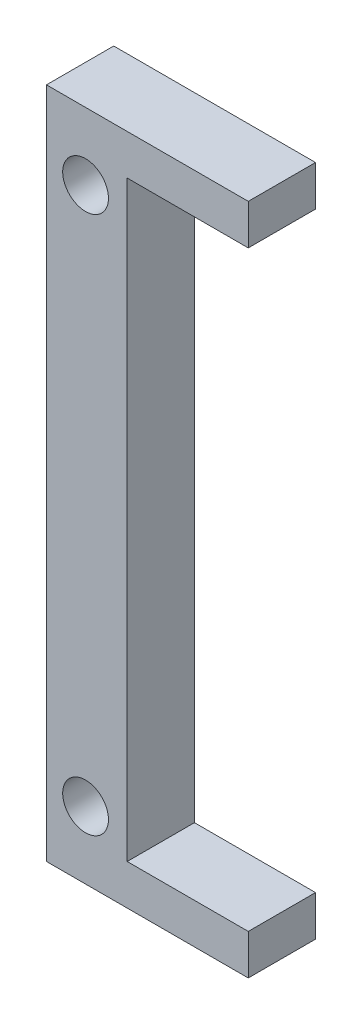
from build123d import *

# Parameters (mm, degrees)
BOSS_EXTRUDE1_DEPTH  = 5
M3_CLEARANCE_HOLE2_D = 3.4


with BuildPart() as part:
    # Sketch1 → Boss-Extrude1 (new body)
    with BuildSketch(Plane.XY):
        Polygon((8.235294118, 15.882352941), (8.235294118, 18.882352941), (-6.764705882, 18.882352941), (-6.764705882, 14.294117647), (-6.764705882, -25.352941176), (-6.764705882, -31.117647059), (-0.882352941, -31.117647059), (8.235294118, -31.117647059), (8.235294118, -28.117647059), (-0.764705882, -28.117647059), (-0.764705882, 15.882352941), align=None)
    extrude(amount=BOSS_EXTRUDE1_DEPTH)

    # M3 Clearance Hole2 (through all)
    with Locations(Plane.XY.offset(5)):
        with Locations((-3.858851748, 13.882352941), (-3.858851748, -26.117647059)):
            Hole(M3_CLEARANCE_HOLE2_D / 2)


solid = part.part
